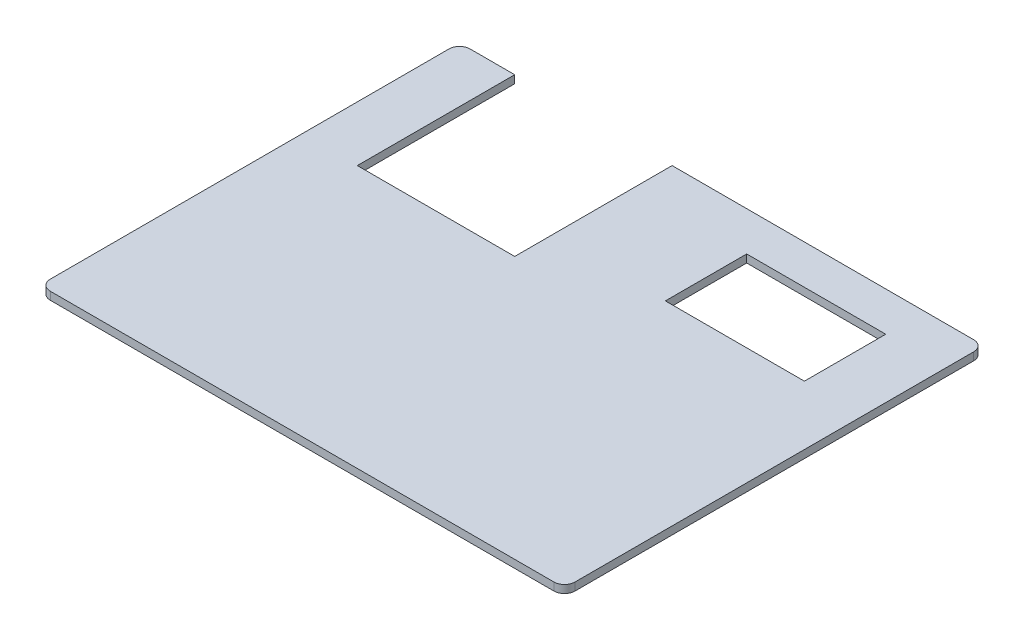
from build123d import *

# Parameters (mm, degrees)
SKETCH1_W           = 100
SKETCH1_H           = 80
BOSS_EXTRUDE1_DEPTH = 1.5
FILLET1_R           = 2
SKETCH7_W           = 30
SKETCH7_H           = 30
BUKAAN_DEPTH        = 7.5
SKETCH8_W           = 26.5
SKETCH8_H           = 15.5
CUT_EXTRUDE6_DEPTH  = 10.5


with BuildPart() as part:
    # Sketch1 → Boss-Extrude1 (new body)
    with BuildSketch(Plane(origin=(0, 0, 0), x_dir=(1, 0, 0), z_dir=(0, 1, 0))):
        with Locations((22.937293729, 8.811881188)):
            Rectangle(SKETCH1_W, SKETCH1_H)
    extrude(amount=BOSS_EXTRUDE1_DEPTH)

    # Fillet1
    fillet1_edges = [part.edges().sort_by_distance(p)[0] for p in [
        (-27.062706271, 0.75, -48.811881188),
        (72.937293729, 0.75, -48.811881188),
        (72.937293729, 0.75, 31.188118812),
        (-27.062706271, 0.75, 31.188118812),
    ]]
    fillet(fillet1_edges, radius=FILLET1_R)

    # Sketch7 → bukaan (cut)
    with BuildSketch(Plane(origin=(0, 1.5, 0), x_dir=(1, 0, 0), z_dir=(0, 1, 0))):
        with Locations((-1.545768262, 33.811881188)):
            Rectangle(SKETCH7_W, SKETCH7_H)
    extrude(amount=-BUKAAN_DEPTH, mode=Mode.SUBTRACT)

    # Sketch8 → Cut-Extrude6 (cut)
    with BuildSketch(Plane(origin=(0, 0, 0), x_dir=(1, 0, 0), z_dir=(0, 1, 0))):
        with Locations((48.400499743, 33.583205548)):
            Rectangle(SKETCH8_W, SKETCH8_H)
    extrude(amount=CUT_EXTRUDE6_DEPTH, mode=Mode.SUBTRACT)


solid = part.part
